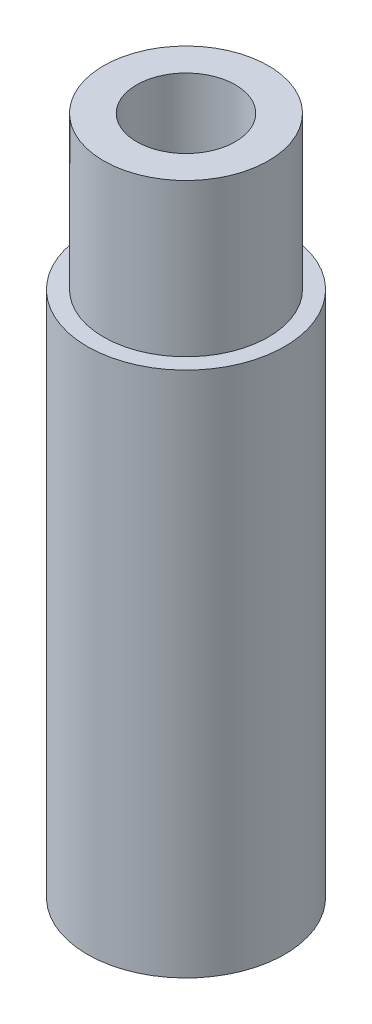
from build123d import *

# Parameters (mm, degrees)
SKETCH1_R           = 4.7625
BOSS_EXTRUDE1_DEPTH = 25.4
SKETCH2_R           = 3.9751
BOSS_EXTRUDE2_DEPTH = 7.366
SKETCH3_R           = 2.38125
CUT_EXTRUDE1_DEPTH  = 33.766
SKETCH4_R           = 3.4544
CUT_EXTRUDE2_DEPTH  = 12.7


with BuildPart() as part:
    # Sketch1 → Boss-Extrude1 (new body)
    with BuildSketch(Plane(origin=(0, 0, 0), x_dir=(1, 0, 0), z_dir=(0, 1, 0))):
        with Locations(Location((0, 0, 0), (0, 0, 270))):  # turned: the seam where the file's is
            Circle(SKETCH1_R)
    extrude(amount=BOSS_EXTRUDE1_DEPTH)

    # Sketch2 → Boss-Extrude2 (add)
    with BuildSketch(Plane(origin=(0, 25.4, 0), x_dir=(1, 0, 0), z_dir=(0, 1, 0))):
        with Locations(Location((0, 0, 0), (0, 0, 270))):  # turned: the seam where the file's is
            Circle(SKETCH2_R)
    extrude(amount=BOSS_EXTRUDE2_DEPTH)

    # Sketch3 → Cut-Extrude1 (cut, through all)
    with BuildSketch(Plane.XZ):
        with Locations(Location((0, 0, 0), (0, 0, 270))):  # turned: the seam where the file's is
            Circle(SKETCH3_R)
    extrude(amount=-CUT_EXTRUDE1_DEPTH, mode=Mode.SUBTRACT)

    # Sketch4 → Cut-Extrude2 (cut)
    with BuildSketch(Plane.XZ):
        with Locations(Location((0, 0, 0), (0, 0, 270))):  # turned: the seam where the file's is
            Circle(SKETCH4_R)
    extrude(amount=-CUT_EXTRUDE2_DEPTH, mode=Mode.SUBTRACT)


solid = part.part
